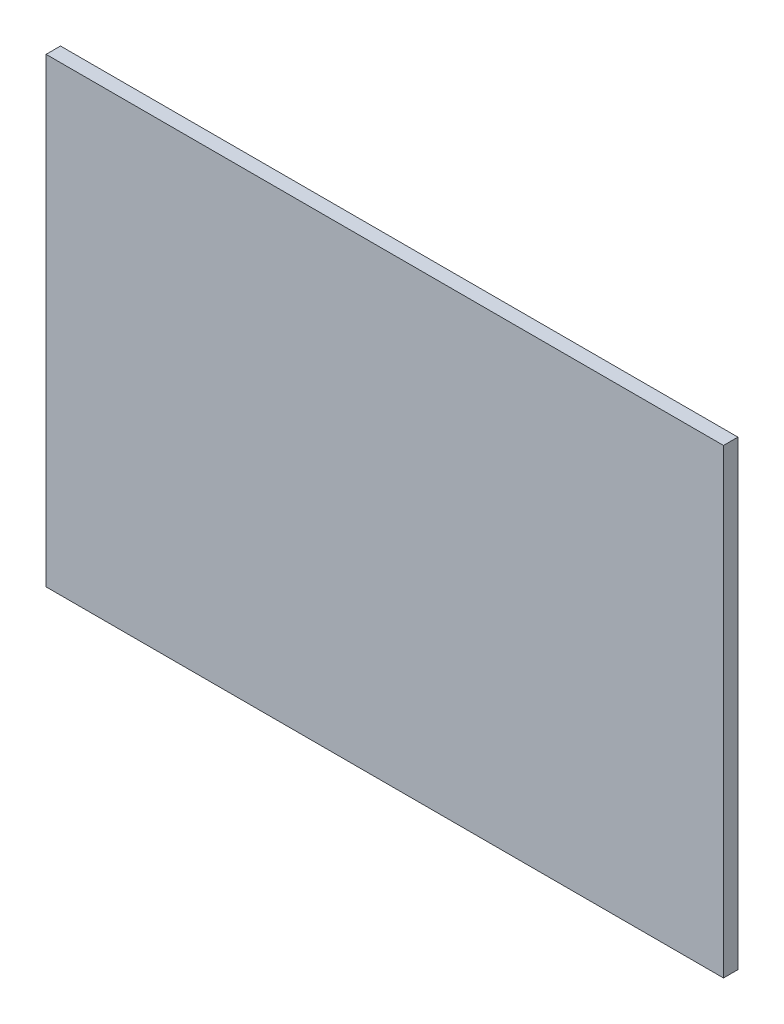
from build123d import *

# Parameters (mm, degrees)
SKETCH1_W           = 149.225
SKETCH1_H           = 101.6
BOSS_EXTRUDE1_DEPTH = 3.175


with BuildPart() as part:
    # Sketch1 → Boss-Extrude1 (new body)
    with BuildSketch(Plane.XY):
        Rectangle(SKETCH1_W, SKETCH1_H)
    extrude(amount=BOSS_EXTRUDE1_DEPTH)


solid = part.part
